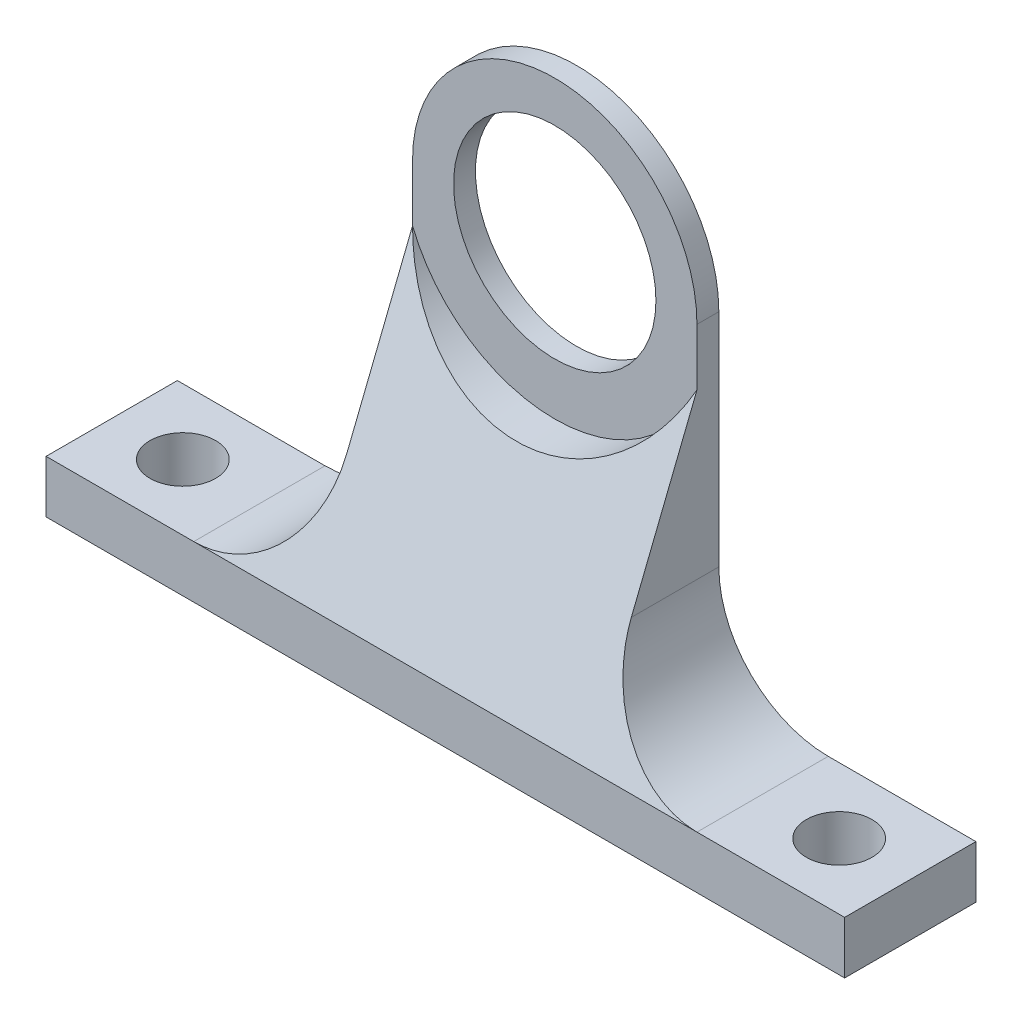
from build123d import *

# Parameters (mm, degrees)
SKETCH1_R           = 9.25
BOSS_EXTRUDE1_DEPTH = 12
SKETCH2_R           = 3
CUT_EXTRUDE1_DEPTH  = 5.8
SKETCH3_R           = 14
CUT_EXTRUDE2_DEPTH  = 10
CUT_EXTRUDE3_DEPTH  = 74


with BuildPart() as part:
    # Sketch1 → Boss-Extrude1 (new body)
    with BuildSketch(Plane.XY):
        with BuildLine():
            Line((-36.5, 0), (36.5, 0))
            Line((36.5, 0), (36.5, 4.8))
            Line((36.5, 4.8), (23, 4.8))
            ThreePointArc((23, 4.8), (15.928932188, 7.728932188), (13, 14.8))
            Line((13, 14.8), (13, 35))
            ThreePointArc((13, 35), (0, 48), (-13, 35))
            Line((-13, 35), (-13, 14.8))
            ThreePointArc((-13, 14.8), (-15.928932188, 7.728932188), (-23, 4.8))
            Line((-23, 4.8), (-36.5, 4.8))
            Line((-36.5, 4.8), (-36.5, 0))
        make_face()
        with Locations((0, 35)):
            Circle(SKETCH1_R, mode=Mode.SUBTRACT)
    extrude(amount=BOSS_EXTRUDE1_DEPTH)

    # Sketch2 → Cut-Extrude1 (cut, through all)
    with BuildSketch(Plane(origin=(0, 4.8, 0), x_dir=(1, 0, 0), z_dir=(0, 1, 0))):
        with Locations(Location((-30, -6, 0), (0, 0, 180))):  # turned: the seam where the file's is
            Circle(SKETCH2_R)
        with Locations(Location((30, -6, 0), (0, 0, 180))):  # turned: the seam where the file's is
            Circle(SKETCH2_R)
    extrude(amount=-CUT_EXTRUDE1_DEPTH, mode=Mode.SUBTRACT)

    # Sketch3 → Cut-Extrude2 (cut)
    with BuildSketch(Plane.XY.offset(12)):
        with Locations((0, 35)):
            Circle(SKETCH3_R)
    extrude(amount=-CUT_EXTRUDE2_DEPTH, mode=Mode.SUBTRACT)

    # Sketch4 → Cut-Extrude3 (cut, through all)
    with BuildSketch(Plane.ZY.offset(36.5)):
        Polygon((2, 29.803847577), (12, 4.8), (12, 29.803847577), align=None)
    extrude(amount=-CUT_EXTRUDE3_DEPTH, mode=Mode.SUBTRACT)


solid = part.part
